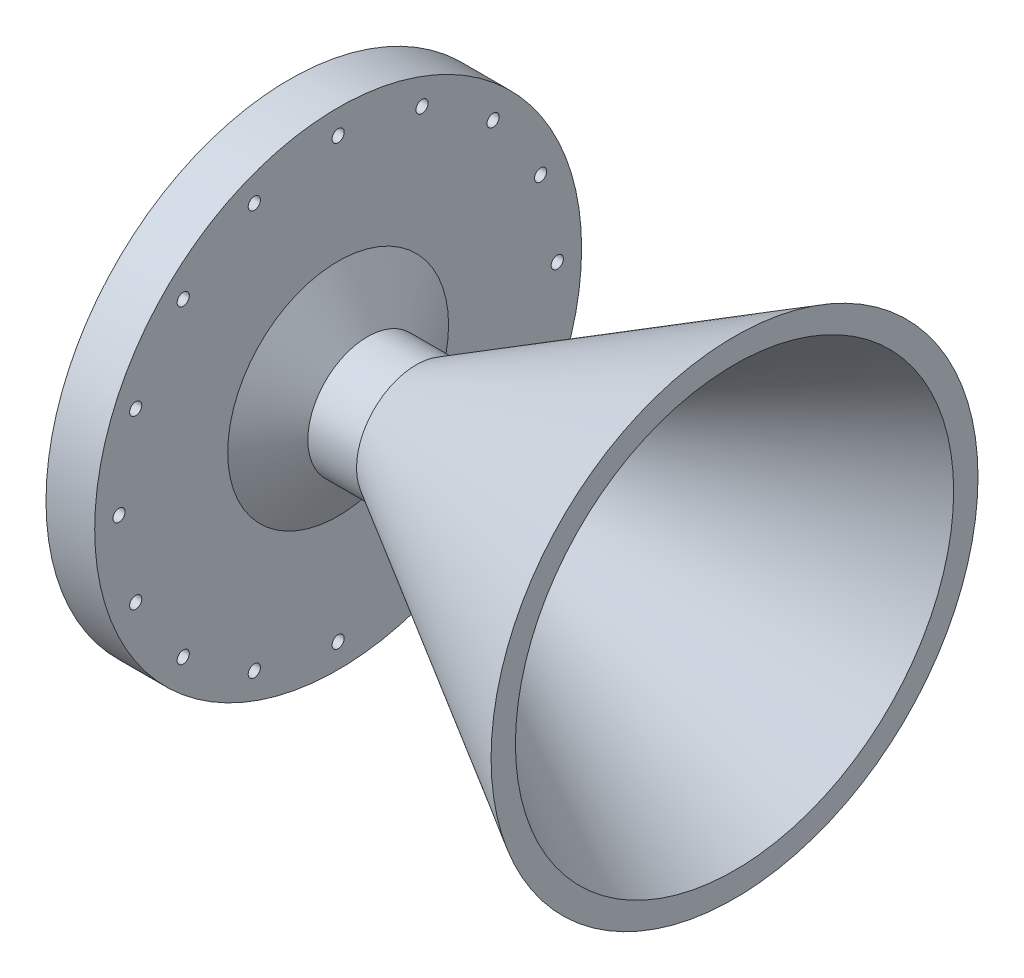
from build123d import *

# Parameters (mm, degrees)
SKETCH2_R          = 50.00625
SKETCH2_R_2        = 47.625
CUT_EXTRUDE1_DEPTH = 1.190625
CUT_EXTRUDE2_REACH = 118.086
SKETCH3_R          = 1.5875


with BuildPart() as part:
    # Sketch1 → Revolve1 (revolve)
    with BuildSketch(Plane.XY):
        Polygon((0, 15.5575), (83.038845842, 63.5), (83.038845842, 57.15), (0, 7.9375), (-12.7, 7.9375), (-33.047266862, 41.275), (-33.047266862, 50.8), (-33.047266862, 63.5), (-20.347266862, 63.5), (-20.347266862, 28.802954744), (-12.7, 15.5575), align=None)
    revolve(axis=Axis((0, 0, 0), (1, 0, 0)))

    # Sketch2 → Cut-Extrude1 (cut)
    with BuildSketch(Plane.ZY.offset(33.047266862)):
        Circle(SKETCH2_R)
        Circle(SKETCH2_R_2, mode=Mode.SUBTRACT)
    extrude(amount=-CUT_EXTRUDE1_DEPTH, mode=Mode.SUBTRACT)

    # Sketch3 → Cut-Extrude2 (cut, up to next)
    with BuildSketch(Plane.ZY.offset(33.047266862), mode=Mode.PRIVATE) as cut_extrude2_sk1:
        with Locations((0, 57.15)):
            Circle(SKETCH3_R)
    cut_extrude2_tool1 = extrude(cut_extrude2_sk1.sketch, amount=-CUT_EXTRUDE2_REACH, mode=Mode.PRIVATE) & part.part
    add(cut_extrude2_tool1.solids().sort_by_distance((-33.047267, 57.15, 0))[0], mode=Mode.SUBTRACT)
    # Sketch3 → Cut-Extrude2 (cut, up to next)
    with BuildSketch(Plane.ZY.offset(33.047266862), mode=Mode.PRIVATE) as cut_extrude2_sk2:
        with Locations((21.87035816, 52.799715283)):
            Circle(SKETCH3_R)
    cut_extrude2_tool2 = extrude(cut_extrude2_sk2.sketch, amount=-CUT_EXTRUDE2_REACH, mode=Mode.PRIVATE) & part.part
    add(cut_extrude2_tool2.solids().sort_by_distance((-33.047267, 52.799715, 21.870358))[0], mode=Mode.SUBTRACT)
    # Sketch3 → Cut-Extrude2 (cut, up to next)
    with BuildSketch(Plane.ZY.offset(33.047266862), mode=Mode.PRIVATE) as cut_extrude2_sk3:
        with Locations((40.411152545, 40.411152545)):
            Circle(SKETCH3_R)
    cut_extrude2_tool3 = extrude(cut_extrude2_sk3.sketch, amount=-CUT_EXTRUDE2_REACH, mode=Mode.PRIVATE) & part.part
    add(cut_extrude2_tool3.solids().sort_by_distance((-33.047267, 40.411153, 40.411153))[0], mode=Mode.SUBTRACT)
    # Sketch3 → Cut-Extrude2 (cut, up to next)
    with BuildSketch(Plane.ZY.offset(33.047266862), mode=Mode.PRIVATE) as cut_extrude2_sk4:
        with Locations((52.799715283, 21.87035816)):
            Circle(SKETCH3_R)
    cut_extrude2_tool4 = extrude(cut_extrude2_sk4.sketch, amount=-CUT_EXTRUDE2_REACH, mode=Mode.PRIVATE) & part.part
    add(cut_extrude2_tool4.solids().sort_by_distance((-33.047267, 21.870358, 52.799715))[0], mode=Mode.SUBTRACT)
    # Sketch3 → Cut-Extrude2 (cut, up to next)
    with BuildSketch(Plane.ZY.offset(33.047266862), mode=Mode.PRIVATE) as cut_extrude2_sk5:
        with Locations((57.15, 0)):
            Circle(SKETCH3_R)
    cut_extrude2_tool5 = extrude(cut_extrude2_sk5.sketch, amount=-CUT_EXTRUDE2_REACH, mode=Mode.PRIVATE) & part.part
    add(cut_extrude2_tool5.solids().sort_by_distance((-33.047267, 0, 57.15))[0], mode=Mode.SUBTRACT)
    # Sketch3 → Cut-Extrude2 (cut, up to next)
    with BuildSketch(Plane.ZY.offset(33.047266862), mode=Mode.PRIVATE) as cut_extrude2_sk6:
        with Locations((52.799715283, -21.87035816)):
            Circle(SKETCH3_R)
    cut_extrude2_tool6 = extrude(cut_extrude2_sk6.sketch, amount=-CUT_EXTRUDE2_REACH, mode=Mode.PRIVATE) & part.part
    add(cut_extrude2_tool6.solids().sort_by_distance((-33.047267, -21.870358, 52.799715))[0], mode=Mode.SUBTRACT)
    # Sketch3 → Cut-Extrude2 (cut, up to next)
    with BuildSketch(Plane.ZY.offset(33.047266862), mode=Mode.PRIVATE) as cut_extrude2_sk7:
        with Locations((40.411152545, -40.411152545)):
            Circle(SKETCH3_R)
    cut_extrude2_tool7 = extrude(cut_extrude2_sk7.sketch, amount=-CUT_EXTRUDE2_REACH, mode=Mode.PRIVATE) & part.part
    add(cut_extrude2_tool7.solids().sort_by_distance((-33.047267, -40.411153, 40.411153))[0], mode=Mode.SUBTRACT)
    # Sketch3 → Cut-Extrude2 (cut, up to next)
    with BuildSketch(Plane.ZY.offset(33.047266862), mode=Mode.PRIVATE) as cut_extrude2_sk8:
        with Locations((21.87035816, -52.799715283)):
            Circle(SKETCH3_R)
    cut_extrude2_tool8 = extrude(cut_extrude2_sk8.sketch, amount=-CUT_EXTRUDE2_REACH, mode=Mode.PRIVATE) & part.part
    add(cut_extrude2_tool8.solids().sort_by_distance((-33.047267, -52.799715, 21.870358))[0], mode=Mode.SUBTRACT)
    # Sketch3 → Cut-Extrude2 (cut, up to next)
    with BuildSketch(Plane.ZY.offset(33.047266862), mode=Mode.PRIVATE) as cut_extrude2_sk9:
        with Locations((0, -57.15)):
            Circle(SKETCH3_R)
    cut_extrude2_tool9 = extrude(cut_extrude2_sk9.sketch, amount=-CUT_EXTRUDE2_REACH, mode=Mode.PRIVATE) & part.part
    add(cut_extrude2_tool9.solids().sort_by_distance((-33.047267, -57.15, 0))[0], mode=Mode.SUBTRACT)
    # Sketch3 → Cut-Extrude2 (cut, up to next)
    with BuildSketch(Plane.ZY.offset(33.047266862), mode=Mode.PRIVATE) as cut_extrude2_sk10:
        with Locations((-21.87035816, -52.799715283)):
            Circle(SKETCH3_R)
    cut_extrude2_tool10 = extrude(cut_extrude2_sk10.sketch, amount=-CUT_EXTRUDE2_REACH, mode=Mode.PRIVATE) & part.part
    add(cut_extrude2_tool10.solids().sort_by_distance((-33.047267, -52.799715, -21.870358))[0], mode=Mode.SUBTRACT)
    # Sketch3 → Cut-Extrude2 (cut, up to next)
    with BuildSketch(Plane.ZY.offset(33.047266862), mode=Mode.PRIVATE) as cut_extrude2_sk11:
        with Locations((-40.411152545, -40.411152545)):
            Circle(SKETCH3_R)
    cut_extrude2_tool11 = extrude(cut_extrude2_sk11.sketch, amount=-CUT_EXTRUDE2_REACH, mode=Mode.PRIVATE) & part.part
    add(cut_extrude2_tool11.solids().sort_by_distance((-33.047267, -40.411153, -40.411153))[0], mode=Mode.SUBTRACT)
    # Sketch3 → Cut-Extrude2 (cut, up to next)
    with BuildSketch(Plane.ZY.offset(33.047266862), mode=Mode.PRIVATE) as cut_extrude2_sk12:
        with Locations((-52.799715283, -21.87035816)):
            Circle(SKETCH3_R)
    cut_extrude2_tool12 = extrude(cut_extrude2_sk12.sketch, amount=-CUT_EXTRUDE2_REACH, mode=Mode.PRIVATE) & part.part
    add(cut_extrude2_tool12.solids().sort_by_distance((-33.047267, -21.870358, -52.799715))[0], mode=Mode.SUBTRACT)
    # Sketch3 → Cut-Extrude2 (cut, up to next)
    with BuildSketch(Plane.ZY.offset(33.047266862), mode=Mode.PRIVATE) as cut_extrude2_sk13:
        with Locations((-57.15, 0)):
            Circle(SKETCH3_R)
    cut_extrude2_tool13 = extrude(cut_extrude2_sk13.sketch, amount=-CUT_EXTRUDE2_REACH, mode=Mode.PRIVATE) & part.part
    add(cut_extrude2_tool13.solids().sort_by_distance((-33.047267, 0, -57.15))[0], mode=Mode.SUBTRACT)
    # Sketch3 → Cut-Extrude2 (cut, up to next)
    with BuildSketch(Plane.ZY.offset(33.047266862), mode=Mode.PRIVATE) as cut_extrude2_sk14:
        with Locations((-52.799715283, 21.87035816)):
            Circle(SKETCH3_R)
    cut_extrude2_tool14 = extrude(cut_extrude2_sk14.sketch, amount=-CUT_EXTRUDE2_REACH, mode=Mode.PRIVATE) & part.part
    add(cut_extrude2_tool14.solids().sort_by_distance((-33.047267, 21.870358, -52.799715))[0], mode=Mode.SUBTRACT)
    # Sketch3 → Cut-Extrude2 (cut, up to next)
    with BuildSketch(Plane.ZY.offset(33.047266862), mode=Mode.PRIVATE) as cut_extrude2_sk15:
        with Locations((-40.411152545, 40.411152545)):
            Circle(SKETCH3_R)
    cut_extrude2_tool15 = extrude(cut_extrude2_sk15.sketch, amount=-CUT_EXTRUDE2_REACH, mode=Mode.PRIVATE) & part.part
    add(cut_extrude2_tool15.solids().sort_by_distance((-33.047267, 40.411153, -40.411153))[0], mode=Mode.SUBTRACT)
    # Sketch3 → Cut-Extrude2 (cut, up to next)
    with BuildSketch(Plane.ZY.offset(33.047266862), mode=Mode.PRIVATE) as cut_extrude2_sk16:
        with Locations((-21.87035816, 52.799715283)):
            Circle(SKETCH3_R)
    cut_extrude2_tool16 = extrude(cut_extrude2_sk16.sketch, amount=-CUT_EXTRUDE2_REACH, mode=Mode.PRIVATE) & part.part
    add(cut_extrude2_tool16.solids().sort_by_distance((-33.047267, 52.799715, -21.870358))[0], mode=Mode.SUBTRACT)


solid = part.part
